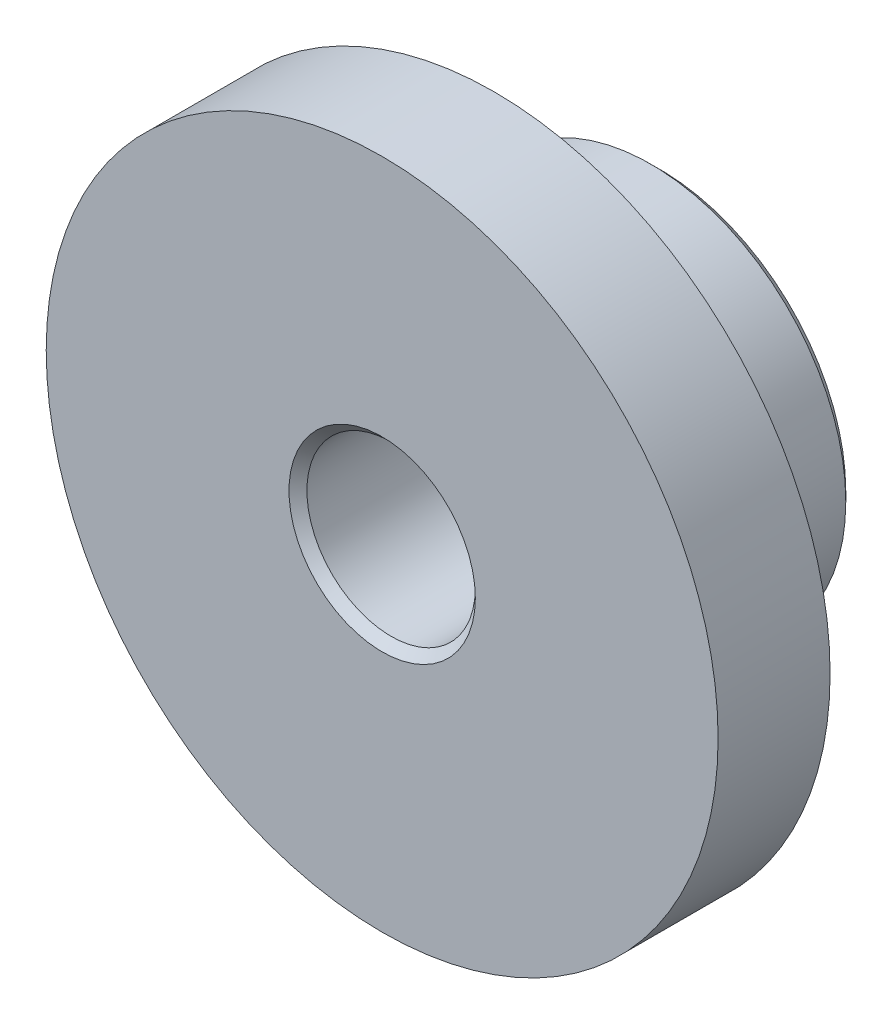
from build123d import *

# Parameters (mm, degrees)
SKETCH1_R          = 19.05
EXTRUDE1_DEPTH     = 15.748
SKETCH2_R          = 19.05
SKETCH2_R_2        = 11.049
CUT_EXTRUDE1_DEPTH = 9.398
SKETCH3_R          = 4.7752
CUT_EXTRUDE2_DEPTH = 12.192
CHAMFER1_SIZE      = 0.508


with BuildPart() as part:
    # Sketch1 → Extrude1 (new body)
    with BuildSketch(Plane.XY):
        Circle(SKETCH1_R)
    extrude(amount=EXTRUDE1_DEPTH)

    # Sketch2 → Cut-Extrude1 (cut)
    with BuildSketch(Plane(origin=(0, 0, 0), x_dir=(-1, 0, 0), z_dir=(0, 0, -1))):
        Circle(SKETCH2_R)
        Circle(SKETCH2_R_2, mode=Mode.SUBTRACT)
    extrude(amount=-CUT_EXTRUDE1_DEPTH, mode=Mode.SUBTRACT)

    # Sketch3 → Cut-Extrude2 (cut)
    with BuildSketch(Plane.XY.offset(15.748)):
        Circle(SKETCH3_R)
    extrude(amount=-CUT_EXTRUDE2_DEPTH, mode=Mode.SUBTRACT)

    # Chamfer1
    chamfer1_edges = [part.edges().sort_by_distance(p)[0] for p in [
        (-4.7752, 0, 15.748),
        (11.049, 0, 0),
    ]]
    chamfer(chamfer1_edges, length=CHAMFER1_SIZE)


solid = part.part
